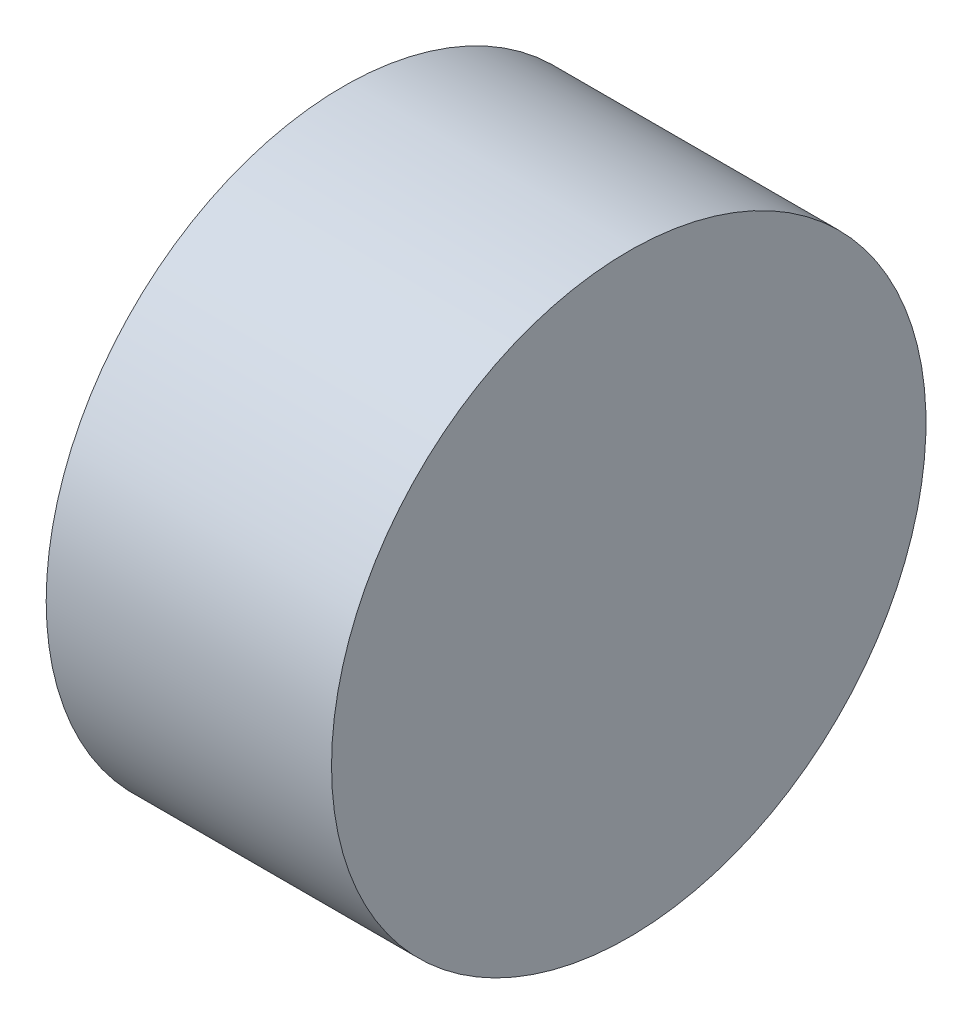
from build123d import *

# Parameters (mm, degrees)
SKETCH_1_W = 6
SKETCH_1_H = 6.25


with BuildPart() as part:
    # 草图1 → 旋转1 (revolve)
    with BuildSketch(Plane.XY, mode=Mode.PRIVATE) as revolve_1_sk:
        with Locations((133.078570246, 41.771589675)):
            Rectangle(SKETCH_1_W, SKETCH_1_H)
    revolve(revolve_1_sk.sketch.rotate(Axis((127.000400996, 38.646589675, 0), (1, 0, 0)), 90), axis=Axis((127.000400996, 38.646589675, 0), (1, 0, 0)))  # turned: the seam where the file's is


solid = part.part
